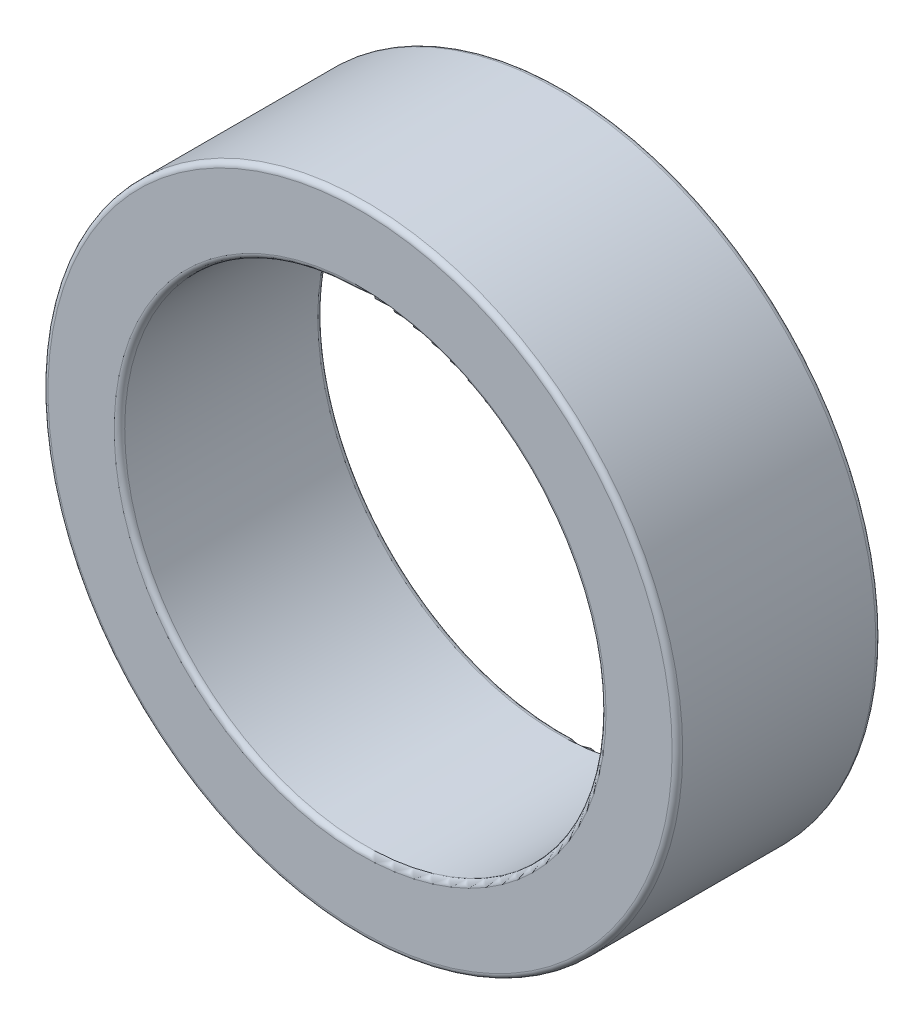
from build123d import *

# Parameters (mm, degrees)
SKETCH1_R           = 6
SKETCH1_R_2         = 4.55
BOSS_EXTRUDE1_DEPTH = 3.85
FILLET1_R           = 0.1


with BuildPart() as part:
    # Sketch1 → Boss-Extrude1 (new body)
    with BuildSketch(Plane.XY):
        Circle(SKETCH1_R)
        Circle(SKETCH1_R_2, mode=Mode.SUBTRACT)
    extrude(amount=BOSS_EXTRUDE1_DEPTH)

    # Fillet1
    fillet1_edges = [part.edges().sort_by_distance(p)[0] for p in [
        (-6, 0, 0),
        (-6, 0, 3.85),
        (-4.55, 0, 0),
        (-4.55, 0, 3.85),
    ]]
    fillet(fillet1_edges, radius=FILLET1_R)


solid = part.part
